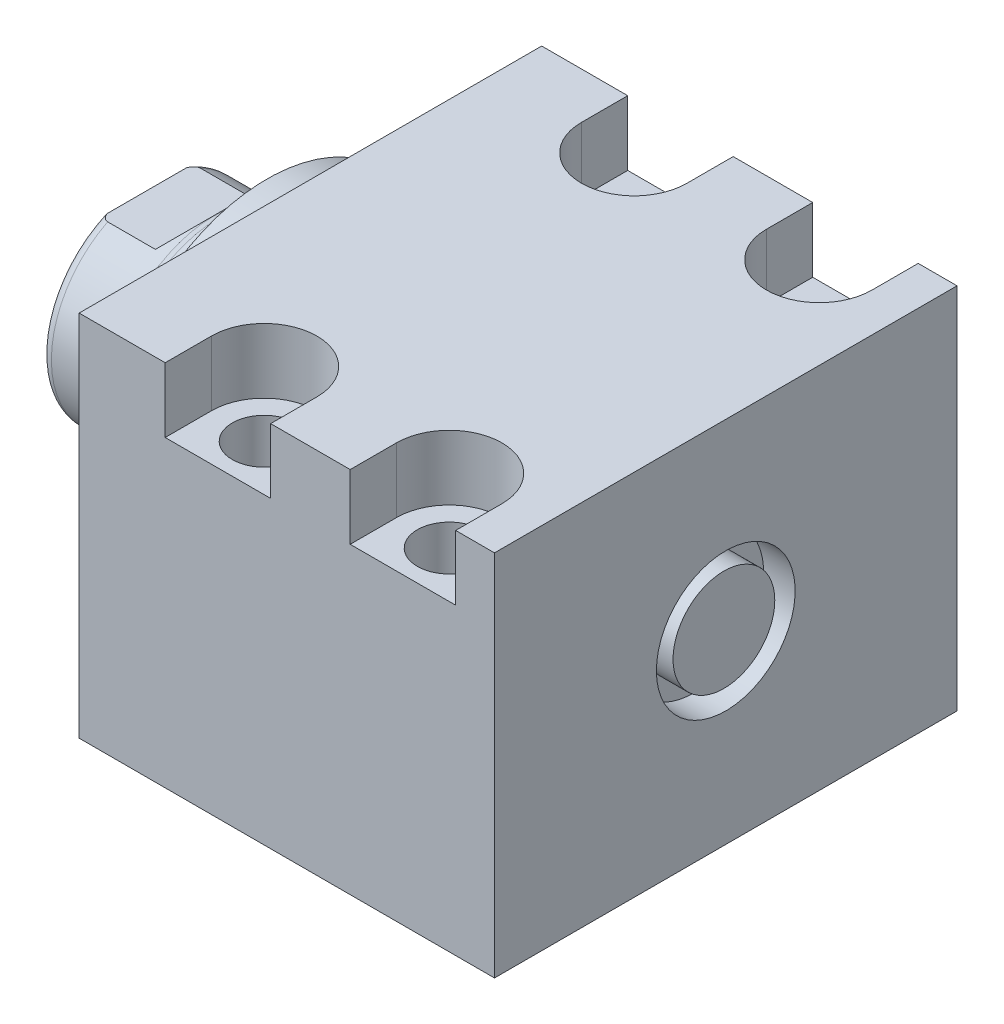
from build123d import *

# Parameters (mm, degrees)
SKETCH1_W          = 63.5
SKETCH1_H          = 50.546
EXTRUDE1_DEPTH     = 57.02
SKETCH5_R          = 22.225
EXTRUDE2_DEPTH     = 5.969
SKETCH6_W          = 14.2875
SKETCH6_H          = 16.511
CUT_EXTRUDE4_DEPTH = 30.48
HOLE2_D            = 8.7376
HOLE2_DEPTH        = 50.546
LPATTERN1_COUNT    = 2
LPATTERN1_PITCH    = 25.4
CUT_EXTRUDE5_DEPTH = 8.89
HOLE3_D            = 3.175
HOLE3_DEPTH        = 9.525
HOLE3_CBORE_D      = 11.3411
HOLE3_CBORE_DEPTH  = 1.4478
HOLE3_TIP          = 0.953866233
HOLE4_D            = 3.175
HOLE4_DEPTH        = 9.525
HOLE4_CBORE_D      = 11.3411
HOLE4_CBORE_DEPTH  = 1.4478
HOLE4_TIP          = 0.953866233
CHAMFER1_SIZE      = 0.635
SKETCH23_R         = 1.4478
LPATTERN3_COUNT    = 2
LPATTERN3_PITCH    = 25.4
SKETCH24_W         = 4.318
SKETCH24_H         = 9.525
SKETCH25_R         = 6.985
EXTRUDE3_DEPTH     = 4.064


with BuildPart() as part:
    # Sketch1 → Extrude1 (new body)
    with BuildSketch(Plane(origin=(0, 0, 0), x_dir=(0, 0, -1), z_dir=(1, 0, 0))):
        with Locations((0, -0.127)):
            Rectangle(SKETCH1_W, SKETCH1_H)
    extrude(amount=EXTRUDE1_DEPTH)

    # Sketch5 → Extrude2 (add)
    with BuildSketch(Plane.ZY):
        with Locations(Location((0, 0, 0), (0, 0, 180))):  # turned: the seam where the file's is
            Circle(SKETCH5_R)
    extrude(amount=EXTRUDE2_DEPTH)

    # Sketch6 → Revolve1 (revolve)
    with BuildSketch(Plane(origin=(0, 0, 0), x_dir=(0, 0, 1), z_dir=(0, -1, 0))):
        with Locations((-7.14375, 14.2245)):
            Rectangle(SKETCH6_W, SKETCH6_H)
    revolve(axis=Axis((5.754582971, 0, 0), (-1, 0, 0)))

    # S2D0001 → Cut-Revolve4 (revolve, cut)
    with BuildSketch(Plane(origin=(-18.511260017, 3.2639, 0), x_dir=(0, 1, 0), z_dir=(0, 0, 1)), mode=Mode.PRIVATE) as cut_revolve4_sk:
        Polygon((2.286, 1.901017728), (2.286, -14.649460017), (-3.2639, -14.649460017), (-3.2639, 3.968739983), (3.4798, 3.968739983), align=None)
    revolve(cut_revolve4_sk.sketch.rotate(Axis((0, 0, 0), (-1, 0, 0)), 90), axis=Axis((0, 0, 0), (-1, 0, 0)), mode=Mode.SUBTRACT)  # turned: the seam where the file's is

    # Sketch8 → Cut-Revolve5 (revolve, cut)
    with BuildSketch(Plane(origin=(0, 0, 0), x_dir=(0, 0, -1), z_dir=(0, 1, 0)), mode=Mode.PRIVATE) as cut_revolve5_sk:
        with BuildLine():
            Line((-14.2875, 12.574), (-14.097, 13.336))
            Line((-14.097, 13.336), (-14.097, 21.464))
            ThreePointArc((-14.097, 21.464), (-13.996678675, 22.007796865), (-13.708922533, 22.48))
            Line((-13.708922533, 22.48), (-14.2875, 22.48))
            Line((-14.2875, 22.48), (-14.2875, 12.574))
        make_face()
    revolve(cut_revolve5_sk.sketch.rotate(Axis((-12.65936, 0, 0), (-1, 0, 0)), 180), axis=Axis((-12.65936, 0, 0), (-1, 0, 0)), mode=Mode.SUBTRACT)  # turned: the seam where the file's is

    # Sketch12 → Cut-Extrude4 (cut, symmetric)
    with BuildSketch(Plane(origin=(0, 0, 0), x_dir=(0, -1, 0), z_dir=(0, 0, -1))):
        Polygon((12.573, 22.48), (12.573, 14.9108), (14.097, 13.3868), (14.097, 22.48), align=None)
        Polygon((-12.573, 22.48), (-12.573, 14.9108), (-14.097, 13.3868), (-14.097, 22.48), align=None)
    extrude(amount=CUT_EXTRUDE4_DEPTH, both=True, mode=Mode.SUBTRACT)

    # Hole2
    with Locations(Plane(origin=(0, 25.146, 0), x_dir=(-1, 0, 0), z_dir=(0, 1, 0))):
        with Locations((-19.05, -25.4), (-19.05, 25.4)):
            hole2 = Hole(HOLE2_D / 2, depth=HOLE2_DEPTH)

    # LPattern1: Hole2 ×2
    with Locations(*[(i * LPATTERN1_PITCH, 0, 0) for i in range(1, LPATTERN1_COUNT)]):
        add(hole2, mode=Mode.SUBTRACT)

    # Sketch18 → Cut-Extrude5 (cut)
    with BuildSketch(Plane(origin=(0, 25.146, 0), x_dir=(1, 0, 0), z_dir=(0, 1, 0))):
        with BuildLine():
            Line((51.689, -31.75), (37.211, -31.75))
            Line((37.211, -31.75), (37.211, -25.4))
            ThreePointArc((37.211, -25.4), (44.45, -18.161), (51.689, -25.4))
            Line((51.689, -25.4), (51.689, -31.75))
        make_face()
        with BuildLine():
            Line((11.811, -25.4), (11.811, -31.75))
            Line((11.811, -31.75), (26.289, -31.75))
            Line((26.289, -31.75), (26.289, -25.4))
            ThreePointArc((26.289, -25.4), (19.05, -18.161), (11.811, -25.4))
        make_face()
        with BuildLine():
            Line((51.689, 25.4), (51.689, 31.75))
            Line((51.689, 31.75), (37.211, 31.75))
            Line((37.211, 31.75), (37.211, 25.4))
            ThreePointArc((37.211, 25.4), (44.45, 18.161), (51.689, 25.4))
        make_face()
        with BuildLine():
            Line((26.289, 31.75), (11.811, 31.75))
            Line((11.811, 31.75), (11.811, 25.4))
            ThreePointArc((11.811, 25.4), (19.05, 18.161), (26.289, 25.4))
            Line((26.289, 25.4), (26.289, 31.75))
        make_face()
    extrude(amount=-CUT_EXTRUDE5_DEPTH, mode=Mode.SUBTRACT)

    # Hole3
    with Locations(Plane.XZ.offset(25.4)):
        with Locations((12.7, 0)):
            CounterBoreHole(HOLE3_D / 2, HOLE3_CBORE_D / 2, HOLE3_CBORE_DEPTH, depth=HOLE3_DEPTH)
            with Locations((0, 0, -(HOLE3_DEPTH + HOLE3_TIP / 2))):  # 118° drill point
                Cone(0, HOLE3_D / 2, HOLE3_TIP, mode=Mode.SUBTRACT)

    # Hole4
    with Locations(Plane.XZ.offset(25.4)):
        with Locations((38.1, 0)):
            CounterBoreHole(HOLE4_D / 2, HOLE4_CBORE_D / 2, HOLE4_CBORE_DEPTH, depth=HOLE4_DEPTH)
            with Locations((0, 0, -(HOLE4_DEPTH + HOLE4_TIP / 2))):  # 118° drill point
                Cone(0, HOLE4_D / 2, HOLE4_TIP, mode=Mode.SUBTRACT)

    # Chamfer1
    chamfer1_edges = [part.edges().sort_by_distance(p)[0] for p in [
        (14.2875, -23.9522, 0),
        (39.6875, -23.9522, 0),
    ]]
    chamfer(chamfer1_edges, length=CHAMFER1_SIZE)

    # Sketch24 → Cut-Revolve6 (revolve, cut)
    with BuildSketch(Plane.XY, mode=Mode.PRIVATE) as cut_revolve6_sk:
        with Locations((54.861, 4.7625)):
            Rectangle(SKETCH24_W, SKETCH24_H)
    revolve(cut_revolve6_sk.sketch.rotate(Axis((0, 0, 0), (1, 0, 0)), 270), axis=Axis((0, 0, 0), (1, 0, 0)), mode=Mode.SUBTRACT)  # turned: the seam where the file's is

    # Sketch25 → Extrude3 (add)
    with BuildSketch(Plane(origin=(52.702, 0, 0), x_dir=(0, 0, -1), z_dir=(1, 0, 0))):
        Circle(SKETCH25_R)
    extrude(amount=EXTRUDE3_DEPTH)


with BuildPart() as body_2:
    # Sketch23 → Revolve2 (revolve)
    with BuildSketch(Plane.XY, mode=Mode.PRIVATE) as revolve2_sk:
        with Locations((8.47725, -25.4)):
            Circle(SKETCH23_R)
    revolve(revolve2_sk.sketch.rotate(Axis((12.7, -23.9522, 0), (0, 1, 0)), 270), axis=Axis((12.7, -23.9522, 0), (0, 1, 0)))  # turned: the seam where the file's is


with BuildPart() as lpattern3_1:
    # LPattern3: pattern copy
    add(body_2.part.moved(Location(Vector(1, 0, 0) * (1 * LPATTERN3_PITCH))))


solid = Compound([part.part, body_2.part, lpattern3_1.part])
